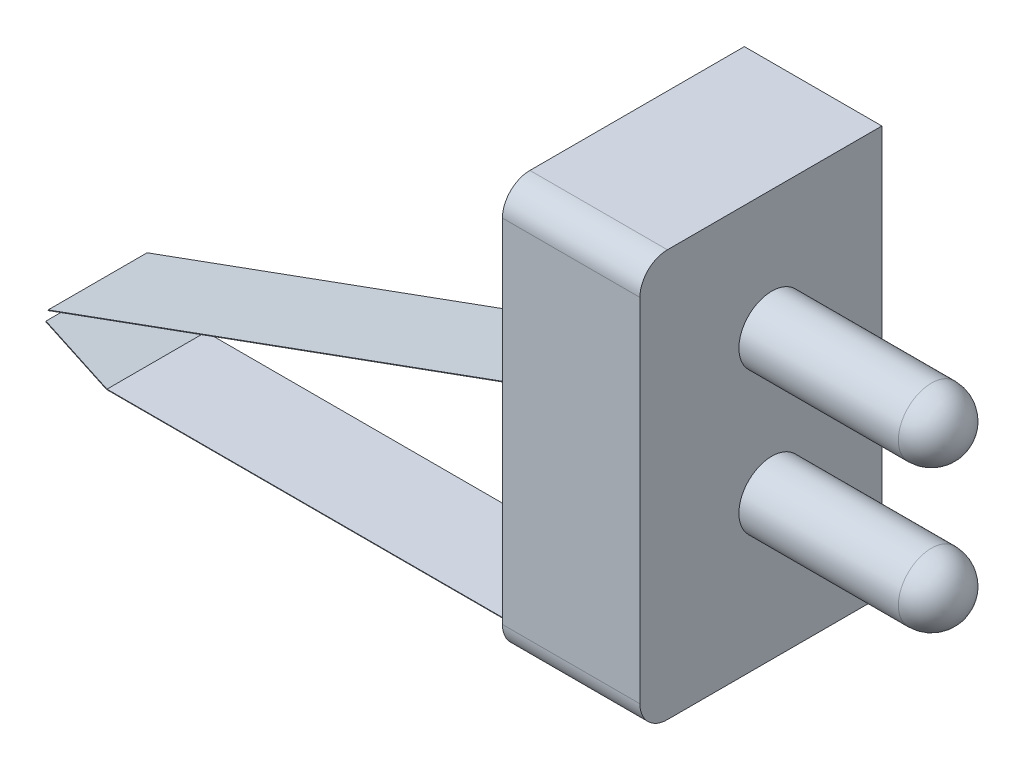
from build123d import *

# Parameters (mm, degrees)
BOSS_EXTRUDE1_DEPTH = 6.35
SKETCH2_R           = 1.524
BOSS_EXTRUDE2_DEPTH = 7.366
DOME1_FACE_RADIUS   = 1.524
DOME1_HEIGHT        = 1.524
DOME2_FACE_RADIUS   = 1.524
DOME2_HEIGHT        = 1.524
BOSS_EXTRUDE3_DEPTH = 4.572
BOSS_EXTRUDE4_DEPTH = 4.572


with BuildPart() as part:
    # Sketch1 → Boss-Extrude1 (new body)
    with BuildSketch(Plane(origin=(0, 0, 0), x_dir=(0, 0, -1), z_dir=(1, 0, 0))):
        with BuildLine():
            Line((-4.318, -9.398), (5.588, -9.398))
            Line((5.588, -9.398), (5.588, 9.398))
            Line((5.588, 9.398), (-4.318, 9.398))
            ThreePointArc((-4.318, 9.398), (-5.216025612, 9.026025612), (-5.588, 8.128))
            Line((-5.588, 8.128), (-5.588, -8.128))
            ThreePointArc((-5.588, -8.128), (-5.216025612, -9.026025612), (-4.318, -9.398))
        make_face()
    extrude(amount=-BOSS_EXTRUDE1_DEPTH)

    # Sketch2 → Boss-Extrude2 (add)
    with BuildSketch(Plane(origin=(0, 0, 0), x_dir=(0, 0, -1), z_dir=(1, 0, 0))):
        with Locations((0.508, -2.794)):
            Circle(SKETCH2_R)
        with Locations((0.508, 3.81)):
            Circle(SKETCH2_R)
    extrude(amount=BOSS_EXTRUDE2_DEPTH)

    # Dome1: a dome of height H over a round flat face of radius A is a cap of a sphere of radius (A * A + H * H) / (2 * H)
    dome1_r = (DOME1_FACE_RADIUS * DOME1_FACE_RADIUS + DOME1_HEIGHT * DOME1_HEIGHT) / (2 * DOME1_HEIGHT)
    dome1_base = Plane((7.366, 3.81, -0.508), z_dir=(1, 0, 0))
    with Locations(dome1_base.offset(DOME1_HEIGHT - dome1_r)):
        dome1_ball = Sphere(dome1_r, mode=Mode.PRIVATE)
    add(split(dome1_ball, bisect_by=dome1_base, keep=Keep.TOP, mode=Mode.PRIVATE))

    # Dome2: a dome of height H over a round flat face of radius A is a cap of a sphere of radius (A * A + H * H) / (2 * H)
    dome2_r = (DOME2_FACE_RADIUS * DOME2_FACE_RADIUS + DOME2_HEIGHT * DOME2_HEIGHT) / (2 * DOME2_HEIGHT)
    dome2_base = Plane((7.366, -2.794, -0.508), z_dir=(1, 0, 0))
    with Locations(dome2_base.offset(DOME2_HEIGHT - dome2_r)):
        dome2_ball = Sphere(dome2_r, mode=Mode.PRIVATE)
    add(split(dome2_ball, bisect_by=dome2_base, keep=Keep.TOP, mode=Mode.PRIVATE))

    # Sketch6 → Boss-Extrude3 (add)
    with BuildSketch(Plane.XY.offset(1.778)):
        with BuildLine():
            Line((-6.35, -3.391509029), (-6.35, -9.68399892))
            ThreePointArc((-6.35, -9.68399892), (-6.935786754, -11.098213246), (-8.35000108, -11.684))
            Line((-8.35000108, -11.684), (-28.448, -11.684))
            Line((-28.448, -11.684), (-31.242, -10.381136403))
            Line((-31.242, -10.381136403), (-31.242, -10.344325173))
            Line((-31.242, -10.344325173), (-28.424812359, -11.6586))
            Line((-28.424812359, -11.6586), (-8.35000108, -11.6586))
            ThreePointArc((-8.35000108, -11.6586), (-6.953747266, -11.080252734), (-6.3754, -9.68399892))
            Line((-6.3754, -9.68399892), (-6.3754, -3.391509029))
            Line((-6.3754, -3.391509029), (-6.35, -3.391509029))
        make_face()
    extrude(amount=-BOSS_EXTRUDE3_DEPTH)

    # Sketch7 → Boss-Extrude4 (add)
    with BuildSketch(Plane.XY.offset(1.778)):
        with BuildLine():
            Line((-6.35, 5.171328303), (-6.35, -0.851509029))
            Line((-6.35, -0.851509029), (-31.14416134, -9.87584574))
            Line((-31.14416134, -9.87584574), (-31.14416134, -9.848815625))
            Line((-31.14416134, -9.848815625), (-6.3754, -0.833723757))
            Line((-6.3754, -0.833723757), (-6.3754, 5.171328303))
            ThreePointArc((-6.3754, 5.171328303), (-6.3627, 5.184028303), (-6.35, 5.171328303))
        make_face()
    extrude(amount=-BOSS_EXTRUDE4_DEPTH)


solid = part.part
